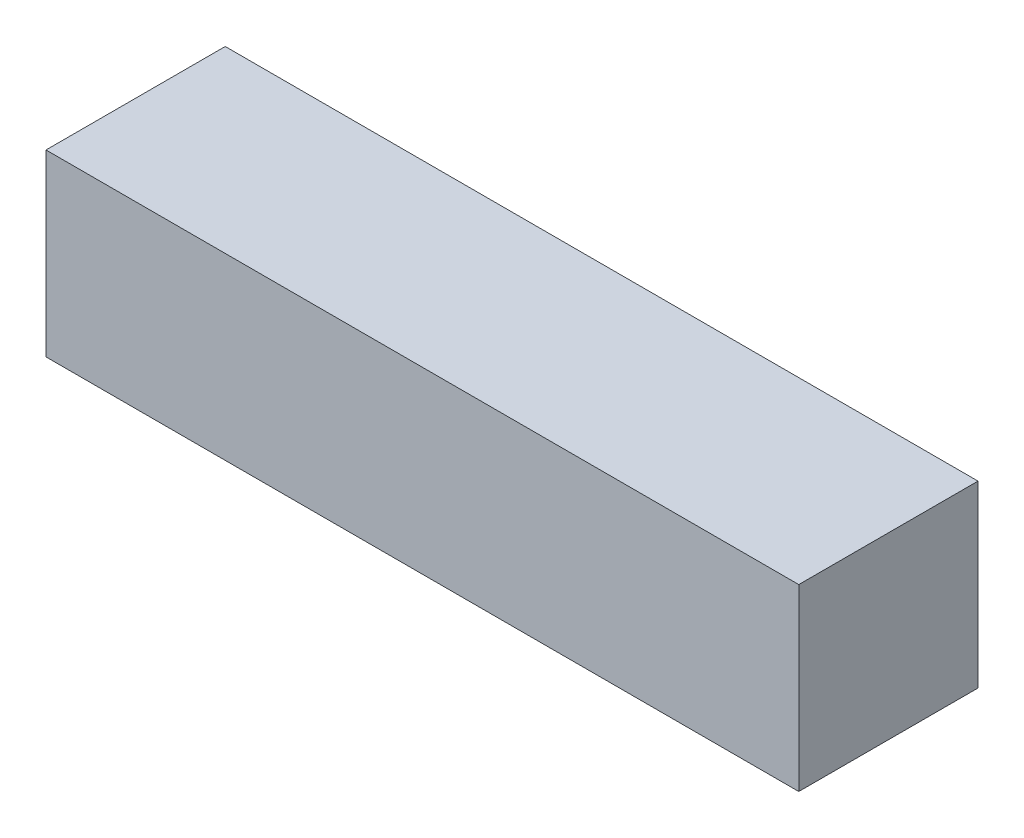
from build123d import *

# Parameters (mm, degrees)
SKETCH_1_W      = 42
SKETCH_1_H      = 10
EXTRUDE_1_DEPTH = 10


with BuildPart() as part:
    # 草圖1 → 填料-伸長1 (new body)
    with BuildSketch(Plane.XY):
        with Locations((-3.09430438, 3.213709677)):
            Rectangle(SKETCH_1_W, SKETCH_1_H)
    extrude(amount=EXTRUDE_1_DEPTH)


solid = part.part
